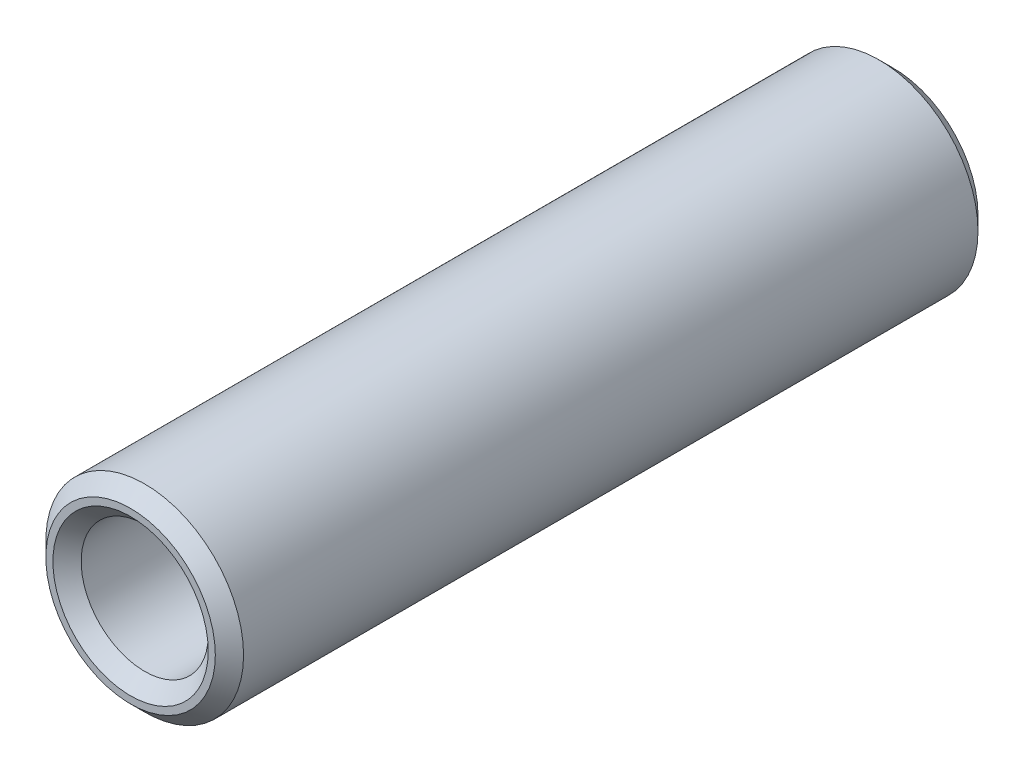
from build123d import *

# Parameters (mm, degrees)
ESQUISSE1_R        = 3.5
ESQUISSE1_R_2      = 2.25
BOSS_EXTRU_1_DEPTH = 27
CHANFREIN2_SIZE    = 0.5
CHANFREIN3_SIZE    = 0.5


with BuildPart() as part:
    # Esquisse1 → Boss.-Extru.1 (new body)
    with BuildSketch(Plane.XY):
        Circle(ESQUISSE1_R)
        Circle(ESQUISSE1_R_2, mode=Mode.SUBTRACT)
    extrude(amount=BOSS_EXTRU_1_DEPTH)

    # Chanfrein2
    chanfrein2_edges = [part.edges().sort_by_distance(p)[0] for p in [
        (-3.5, 0, 0),
        (-2.25, 0, 0),
    ]]
    chamfer(chanfrein2_edges, length=CHANFREIN2_SIZE)

    # Chanfrein3
    chanfrein3_edges = [part.edges().sort_by_distance(p)[0] for p in [
        (-3.5, 0, 27),
        (-2.25, 0, 27),
    ]]
    chamfer(chanfrein3_edges, length=CHANFREIN3_SIZE)


solid = part.part
